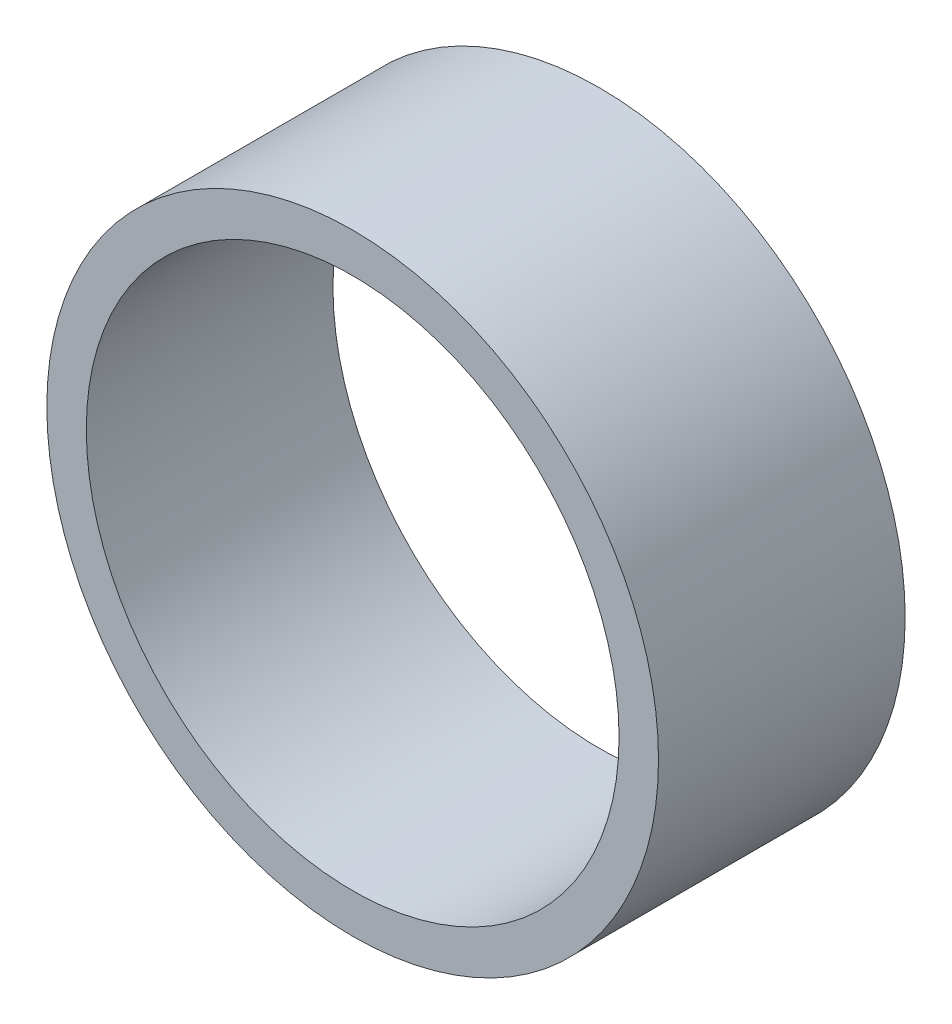
from build123d import *

# Parameters (mm, degrees)
ESQUISSE1_R        = 31
ESQUISSE1_R_2      = 27
BOSS_EXTRU_1_DEPTH = 25


with BuildPart() as part:
    # Esquisse1 → Boss.-Extru.1 (new body)
    with BuildSketch(Plane.XY):
        Circle(ESQUISSE1_R)
        Circle(ESQUISSE1_R_2, mode=Mode.SUBTRACT)
    extrude(amount=BOSS_EXTRU_1_DEPTH)


solid = part.part
